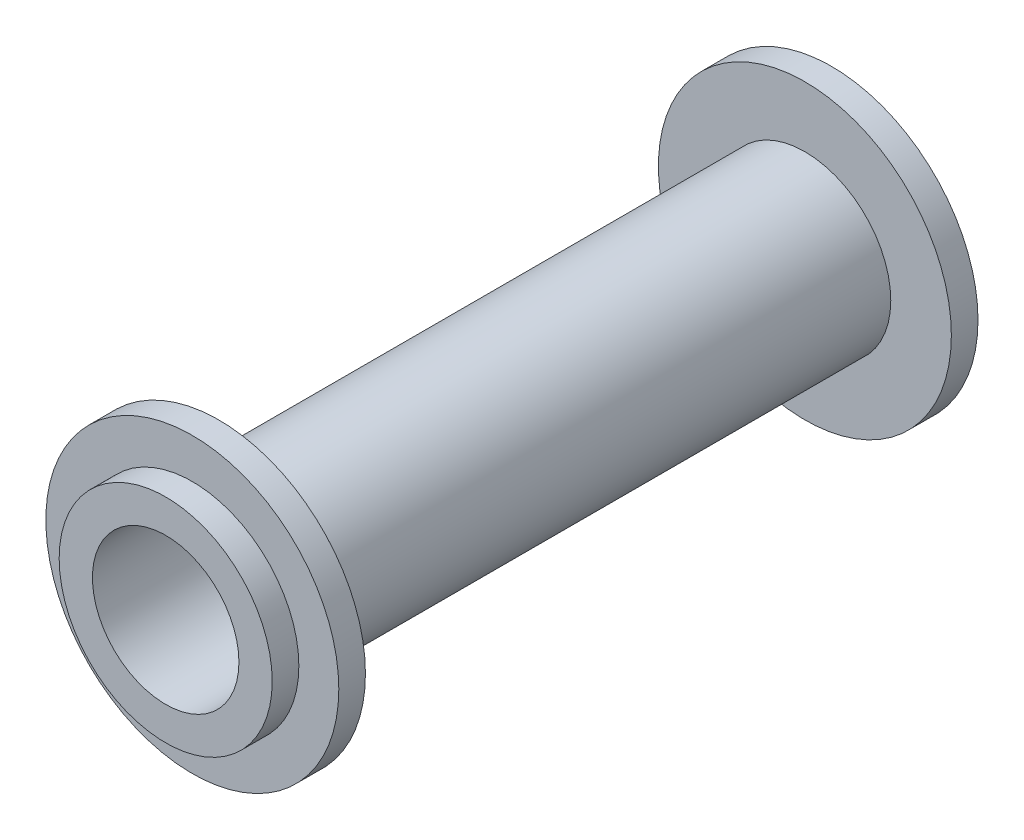
from build123d import *


with BuildPart() as part:
    # Sketch1 → Revolve1 (revolve)
    with BuildSketch(Plane(origin=(0, 0, 0), x_dir=(0, 0, -1), z_dir=(1, 0, 0))):
        Polygon((0, 5.5), (52, 5.5), (52, 8), (50, 8), (50, 11), (48, 11), (48, 6.45), (4, 6.45), (4, 11), (2, 11), (2, 8), (0, 8), align=None)
    revolve(axis=Axis((0, 0, 0), (0, 0, -1)))


solid = part.part
